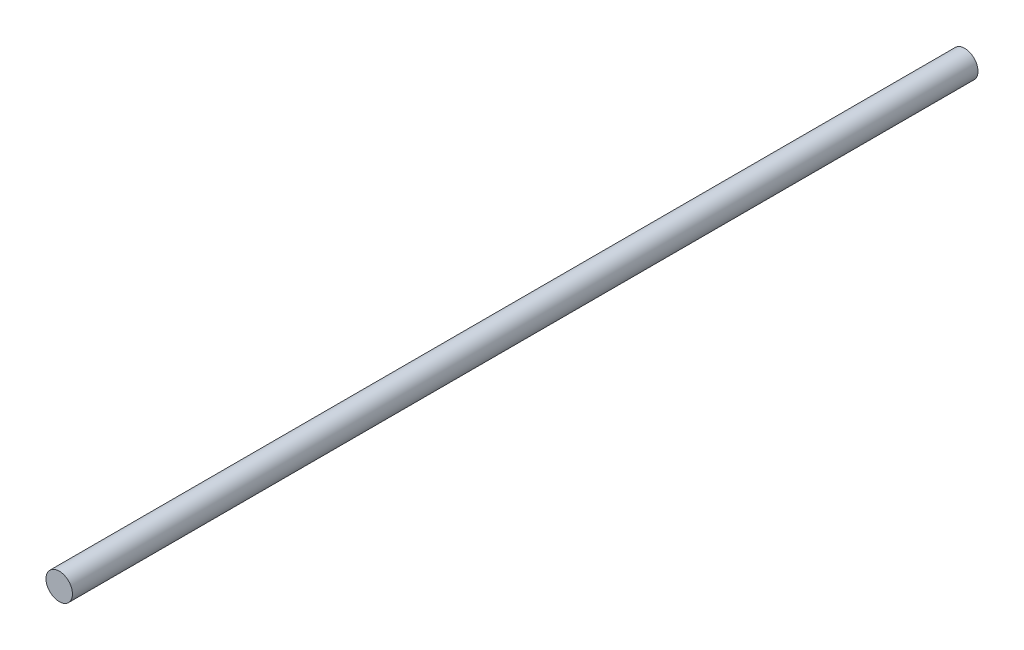
from build123d import *

# Parameters (mm, degrees)
SKETCH1_R           = 3.95
BOSS_EXTRUDE1_DEPTH = 270


with BuildPart() as part:
    # Sketch1 → Boss-Extrude1 (new body)
    with BuildSketch(Plane.XY):
        Circle(SKETCH1_R)
    extrude(amount=BOSS_EXTRUDE1_DEPTH)


solid = part.part
